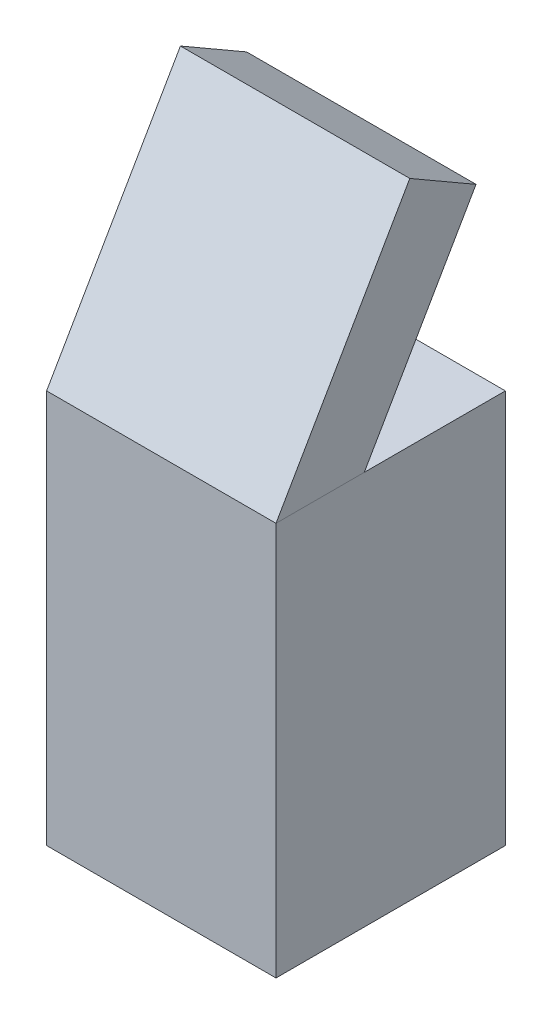
from build123d import *

# Parameters (mm, degrees)
SKETCH_1_W      = 600
SKETCH_1_H      = 600
EXTRUDE_1_DEPTH = 1030
EXTRUDE_2_DEPTH = 600


with BuildPart() as part:
    # 草图1 → 拉伸1 (new body)
    with BuildSketch(Plane(origin=(0, 0, 0), x_dir=(1, 0, 0), z_dir=(0, 1, 0))):
        Rectangle(SKETCH_1_W, SKETCH_1_H)
    extrude(amount=EXTRUDE_1_DEPTH)


with BuildPart() as body_2:
    # 草图4 → 拉伸2 (new body)
    with BuildSketch(Plane(origin=(300, 0, 0), x_dir=(0, 0, -1), z_dir=(1, 0, 0))):
        Polygon((-300, 1030), (50, 1636.217782649), (223.205080757, 1536.217782649), (-69.059892324, 1030), align=None)
    extrude(amount=-EXTRUDE_2_DEPTH)


solid = Compound([part.part, body_2.part])
